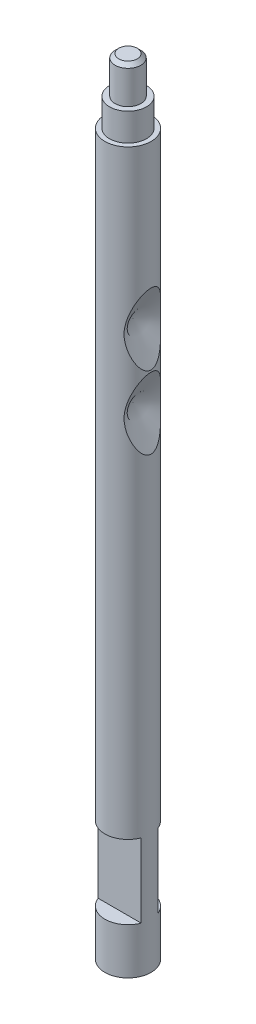
from build123d import *

# Parameters (mm, degrees)
SKETCH1_R               = 1.25
BOSS_EXTRUDE1_DEPTH     = 42.5
SKETCH2_OUTSIDE_W       = 13.03
SKETCH2_OUTSIDE_H       = 13.03
SKETCH2_OUTSIDE_R       = 1
CUT_EXTRUDE1_DEPTH      = 3.5
SKETCH3_OUTSIDE_W       = 13.03
SKETCH3_OUTSIDE_H       = 13.03
SKETCH3_OUTSIDE_R       = 0.7
CUT_EXTRUDE2_DEPTH      = 2
CHAMFER1_SIZE           = 0.2
SKETCH4_W               = 0.8
SKETCH4_H               = 4
CUT_EXTRUDE3_DEPTH      = 2.25
CUT_EXTRUDE3_DEPTH_BACK = 2.25
LPATTERN1_COUNT         = 2
LPATTERN1_PITCH         = 3.95


with BuildPart() as part:
    # Sketch1 → Boss-Extrude1 (new body)
    with BuildSketch(Plane(origin=(0, 0, 0), x_dir=(1, 0, 0), z_dir=(0, 1, 0))):
        Circle(SKETCH1_R)
    extrude(amount=BOSS_EXTRUDE1_DEPTH)

    # Sketch2 outside → Cut-Extrude1 (cut)
    with BuildSketch(Plane(origin=(0, 42.5, 0), x_dir=(1, 0, 0), z_dir=(0, 1, 0))):
        Rectangle(SKETCH2_OUTSIDE_W, SKETCH2_OUTSIDE_H)
        Circle(SKETCH2_OUTSIDE_R, mode=Mode.SUBTRACT)
    extrude(amount=-CUT_EXTRUDE1_DEPTH, mode=Mode.SUBTRACT)

    # Sketch3 outside → Cut-Extrude2 (cut)
    with BuildSketch(Plane(origin=(0, 42.5, 0), x_dir=(1, 0, 0), z_dir=(0, 1, 0))):
        Rectangle(SKETCH3_OUTSIDE_W, SKETCH3_OUTSIDE_H)
        Circle(SKETCH3_OUTSIDE_R, mode=Mode.SUBTRACT)
    extrude(amount=-CUT_EXTRUDE2_DEPTH, mode=Mode.SUBTRACT)

    # Chamfer1
    chamfer1_edges = [part.edges().sort_by_distance(p)[0] for p in [
        (-0.7, 42.5, 0),
    ]]
    chamfer(chamfer1_edges, length=CHAMFER1_SIZE)

    # Sketch4 → Cut-Extrude3 (cut, two sides)
    with BuildSketch(Plane(origin=(0, 0, 0), x_dir=(0, 0, -1), z_dir=(1, 0, 0))) as cut_extrude3_sk:
        with Locations((0.85, 4.5)):
            Rectangle(SKETCH4_W, SKETCH4_H)
        with Locations((-0.85, 4.5)):
            Rectangle(SKETCH4_W, SKETCH4_H)
    extrude(amount=CUT_EXTRUDE3_DEPTH, mode=Mode.SUBTRACT)
    extrude(cut_extrude3_sk.sketch, amount=-CUT_EXTRUDE3_DEPTH_BACK, mode=Mode.SUBTRACT)

    # Sketch5 → Cut-Revolve2 (revolve, cut)
    with BuildSketch(Plane.XY):
        Polygon((1.25, 32.123358295), (0.27, 30.2), (1.25, 30.2), align=None)
    cut_revolve2 = revolve(axis=Axis((0.27, 30.2, 0), (1, 0, 0)), mode=Mode.SUBTRACT)

    # LPattern1: Cut-Revolve2 ×2
    with Locations(*[(0, -i * LPATTERN1_PITCH, 0) for i in range(1, LPATTERN1_COUNT)]):
        add(cut_revolve2, mode=Mode.SUBTRACT)


solid = part.part
